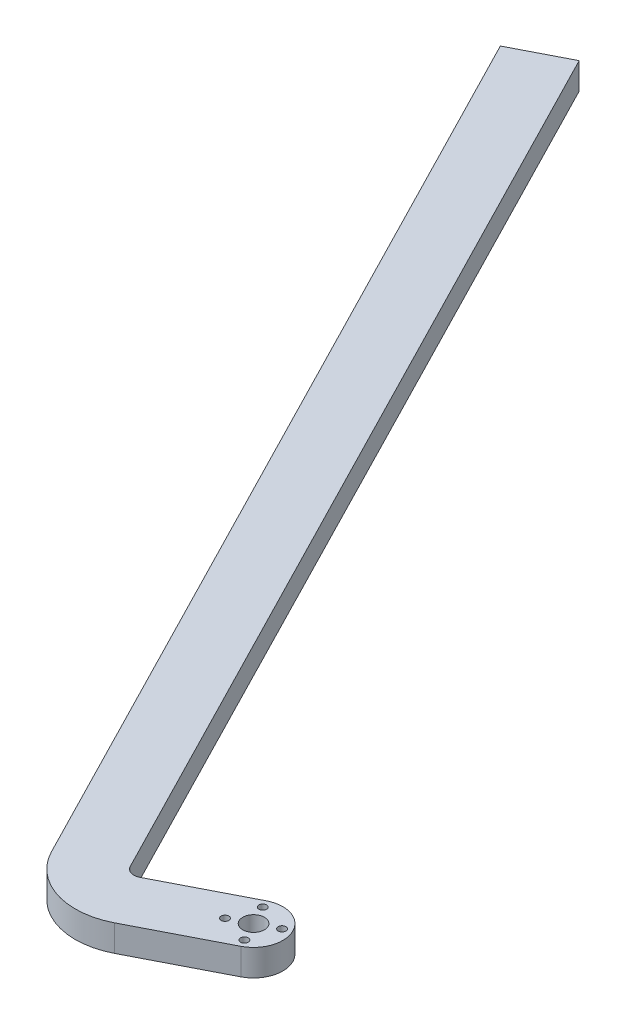
from build123d import *

# Parameters (mm, degrees)
SKETCH2_R           = 4.1
SKETCH2_R_2         = 1.455
BOSS_EXTRUDE2_DEPTH = 10


with BuildPart() as part:
    # Sketch2 → Boss-Extrude2 (new body)
    with BuildSketch(Plane(origin=(0, 0, 0), x_dir=(-1, 0, 0), z_dir=(0, 1, 0))):
        with BuildLine():
            Line((5.045766375, -9.830704028), (36.565058692, 6.347077836))
            ThreePointArc((36.565058692, 6.347077836), (39.606684002, 6.595535729), (41.933124145, 4.620468108))
            Line((41.933124145, 4.620468108), (220.6412412, -343.557880956))
            Line((220.6412412, -343.557880956), (240.302649257, -333.466348206))
            Line((240.302649257, -333.466348206), (61.594532201, 14.712000858))
            ThreePointArc((61.594532201, 14.712000858), (46.373607726, 27.634041934), (26.473525942, 26.008485892))
            Line((26.473525942, 26.008485892), (-5.045766375, 9.830704028))
            ThreePointArc((-5.045766375, 9.830704028), (-9.830704028, -5.045766375), (5.045766375, -9.830704028))
        make_face()
        Circle(SKETCH2_R, mode=Mode.SUBTRACT)
        with Locations((-3.653043529, 7.117251785)):
            Circle(SKETCH2_R_2, mode=Mode.SUBTRACT)
        with Locations((7.117251785, 3.653043529)):
            Circle(SKETCH2_R_2, mode=Mode.SUBTRACT)
        with Locations((-7.117251785, -3.653043529)):
            Circle(SKETCH2_R_2, mode=Mode.SUBTRACT)
        with Locations((3.653043529, -7.117251785)):
            Circle(SKETCH2_R_2, mode=Mode.SUBTRACT)
    extrude(amount=BOSS_EXTRUDE2_DEPTH)


solid = part.part
